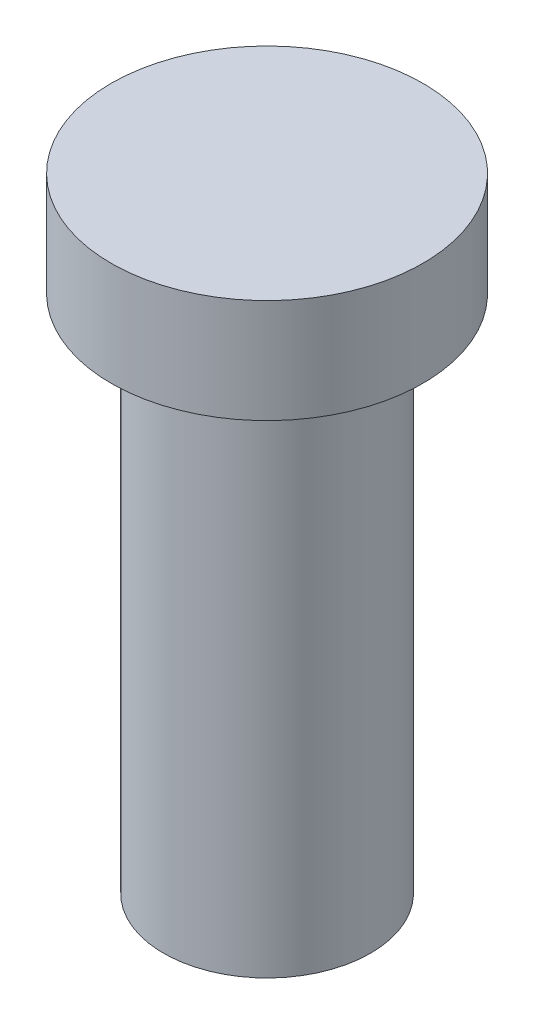
from build123d import *


with BuildPart() as part:
    # Sketch1 → Revolve1 (revolve)
    with BuildSketch(Plane.XY):
        Polygon((0, 0), (6.3246, 0), (6.3246, 31.75), (9.525, 31.75), (9.525, 38.1), (0, 38.1), align=None)
    revolve(axis=Axis((0, 38.1, 0), (0, -1, 0)))


solid = part.part
